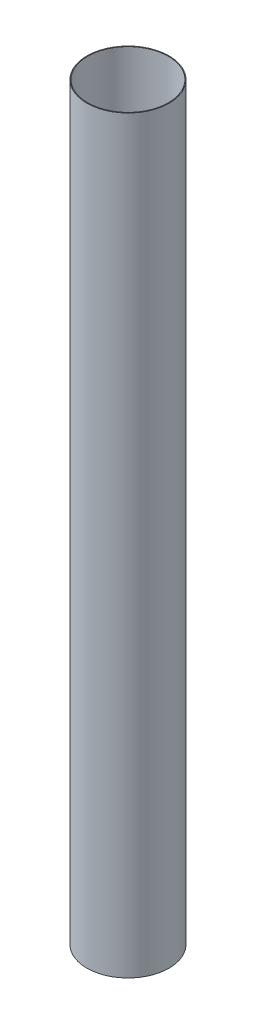
from build123d import *

# Parameters (mm, degrees)
SKETCH1_R           = 90.4875
SKETCH1_R_2         = 88.9
BOSS_EXTRUDE1_DEPTH = 1651


with BuildPart() as part:
    # Sketch1 → Boss-Extrude1 (new body)
    with BuildSketch(Plane(origin=(0, 0, 0), x_dir=(1, 0, 0), z_dir=(0, 1, 0))):
        Circle(SKETCH1_R)
        Circle(SKETCH1_R_2, mode=Mode.SUBTRACT)
    extrude(amount=BOSS_EXTRUDE1_DEPTH)


solid = part.part
